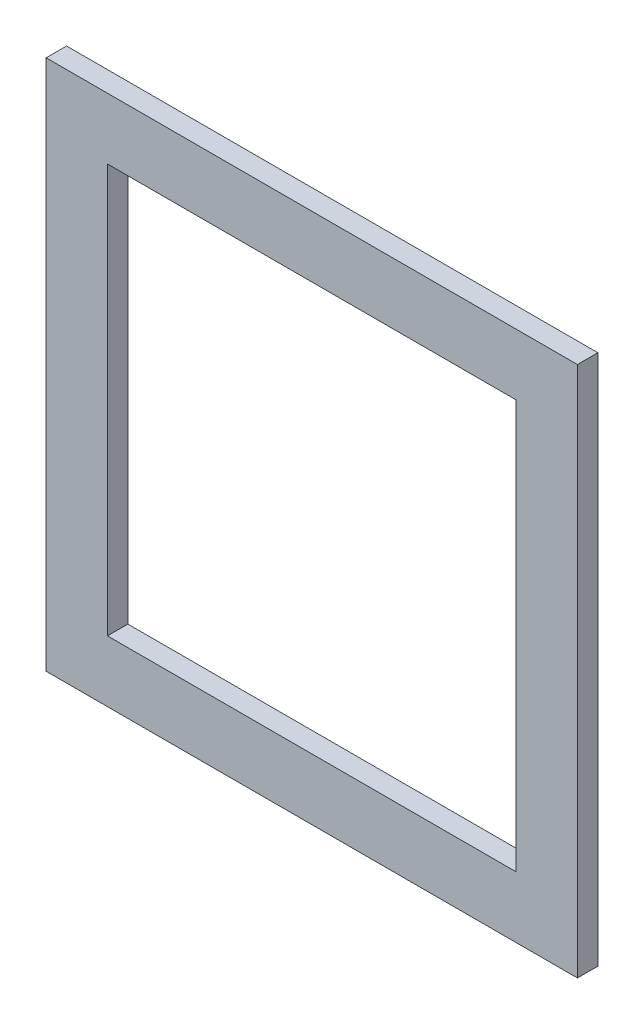
from build123d import *

# Parameters (mm, degrees)
SCHIZZO1_W                   = 130
SCHIZZO1_H                   = 130
ESTRUSIONE_ESTRUSIONE1_DEPTH = 5
SCHIZZO2_W                   = 100
SCHIZZO2_H                   = 100
TAGLIO_ESTRUSIONE1_DEPTH     = 5


with BuildPart() as part:
    # Schizzo1 → Estrusione-Estrusione1 (new body)
    with BuildSketch(Plane.XY):
        Rectangle(SCHIZZO1_W, SCHIZZO1_H)
    extrude(amount=ESTRUSIONE_ESTRUSIONE1_DEPTH)

    # Schizzo2 → Taglio-Estrusione1 (cut)
    with BuildSketch(Plane.XY.offset(5)):
        Rectangle(SCHIZZO2_W, SCHIZZO2_H)
    extrude(amount=-TAGLIO_ESTRUSIONE1_DEPTH, mode=Mode.SUBTRACT)


solid = part.part
